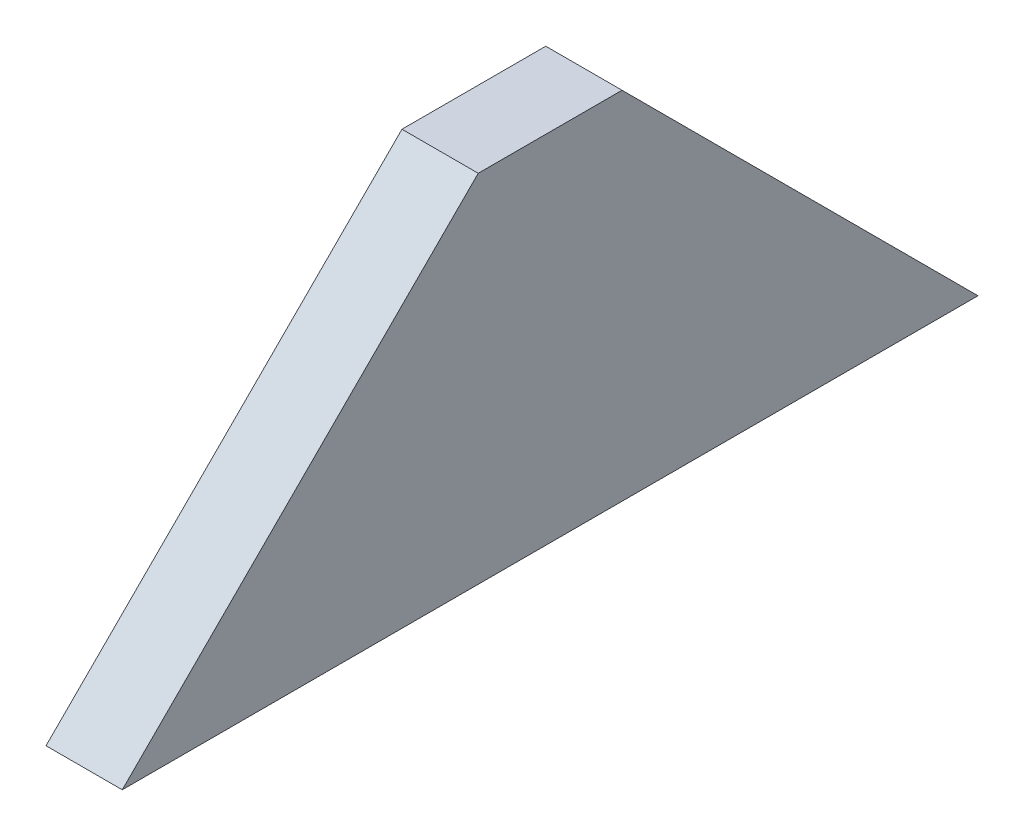
from build123d import *

# Parameters (mm, degrees)
EXTRUDE1_DEPTH = 19.05


with BuildPart() as part:
    # Sketch1 → Extrude1 (new body)
    with BuildSketch(Plane(origin=(0, 0, 0), x_dir=(0, 0, -1), z_dir=(1, 0, 0))):
        Polygon((74.341463415, 18.430487805), (110.257063415, 18.430487805), (199.157063415, -70.469512195), (-14.558536585, -70.469512195), align=None)
    extrude(amount=-EXTRUDE1_DEPTH)


solid = part.part
